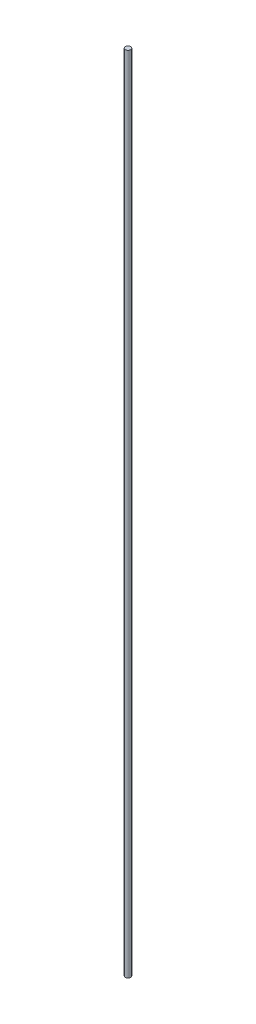
from build123d import *

# Parameters (mm, degrees)
SKETCH1_R           = 1
BOSS_EXTRUDE1_DEPTH = 300


with BuildPart() as part:
    # Sketch1 → Boss-Extrude1 (new body)
    with BuildSketch(Plane(origin=(0, 0, 0), x_dir=(1, 0, 0), z_dir=(0, 1, 0))):
        Circle(SKETCH1_R)
    extrude(amount=BOSS_EXTRUDE1_DEPTH)


solid = part.part
